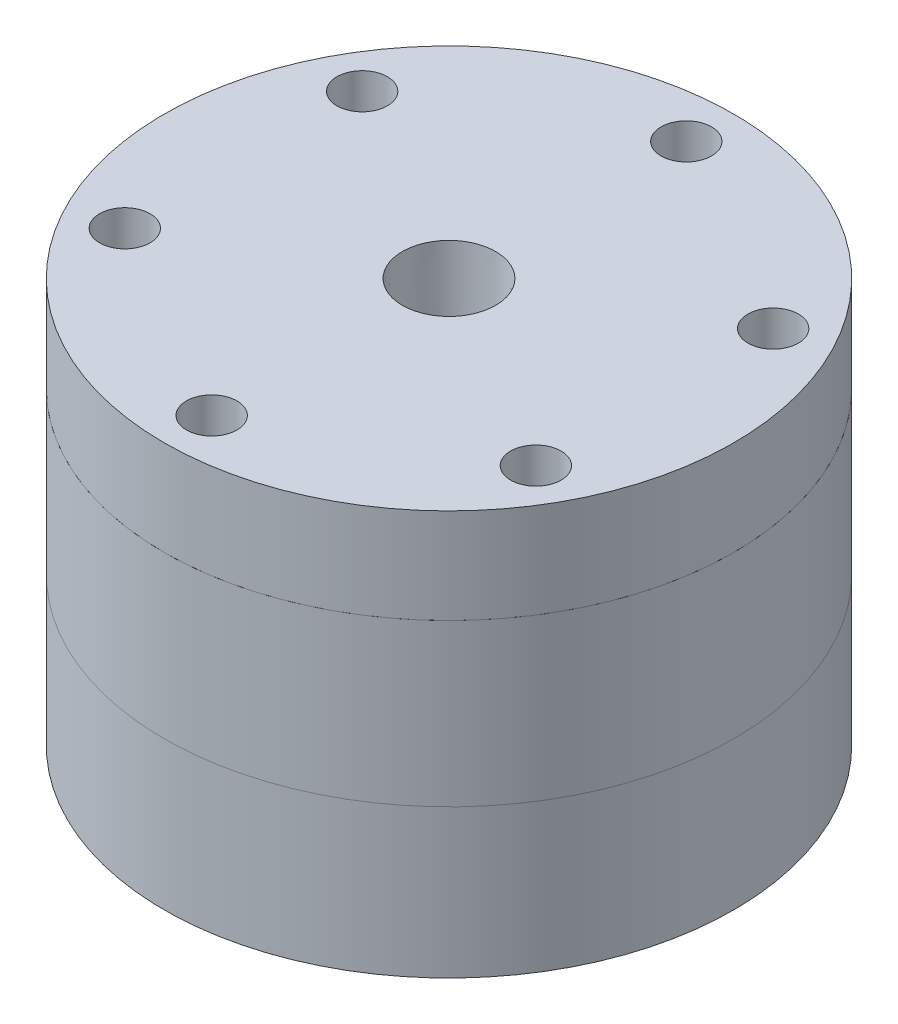
from build123d import *

# Parameters (mm, degrees)
SKETCH21_W          = 19.05
SKETCH21_H          = 13.4874
SKETCH13_R          = 38.1
BOSS_EXTRUDE1_DEPTH = 12.7
SKETCH15_W          = 3.3782
SKETCH15_H          = 54.1274
CIRPATTERN1_COUNT   = 6


with BuildPart() as part:
    # Sketch1 → Revolve1 (revolve)
    with BuildSketch(Plane.XY):
        Polygon((-25.5524, 0), (-38.1, 0), (-38.1, -21.59), (-25.5524, -21.59), (-25.5524, -18.8976), (-21.4884, -18.8976), (-21.4884, -21.59), (-11.9761, -21.59), (-11.9761, -19.6088), (-8.9027, -19.6088), (-8.9027, -21.59), (-7.62, -21.59), (-7.62, -18.415), (-10.795, -15.24), (-15.875, -15.24), (-15.875, 0), (-21.4884, 0), (-21.4884, -2.6924), (-25.5524, -2.6924), align=None)
    revolve(axis=Axis((0, -86.75, 0), (0, 1, 0)))


with BuildPart() as body_2:
    # Sketch21 → Revolve7 (revolve)
    with BuildSketch(Plane.XY):
        with Locations((-28.575, -28.3337)):
            Rectangle(SKETCH21_W, SKETCH21_H)
    revolve(axis=Axis((0, -86.75, 0), (0, 1, 0)))

    # Sketch4 → Revolve5 (revolve)
    with BuildSketch(Plane.XY):
        Polygon((-6.35, -35.0774), (-38.1, -35.0774), (-38.1, -41.4274), (-11.1125, -41.4274), (-6.35, -36.6649), align=None)
    revolve(axis=Axis((0, -86.75, 0), (0, 1, 0)))

    # Sketch10 → 1/4 NPT Tapped Hole3 (revolve, cut)
    with BuildSketch(Plane(origin=(-38.1, -30.6324, 0), x_dir=(0, 0, 1), z_dir=(0, 1, 0))):
        Polygon((0, 0), (0, 25.694347279), (5.5626, 22.352), (5.5626, 9.906), (5.943685794, 9.906), (6.2402847, 0), align=None)
    revolve(axis=Axis((-44.45, -30.6324, 0), (1, 0, 0)), mode=Mode.SUBTRACT)


with BuildPart() as body_3:
    # Sketch13 → Boss-Extrude1 (new body)
    with BuildSketch(Plane(origin=(0, 0, 0), x_dir=(1, 0, 0), z_dir=(0, 1, 0))):
        Circle(SKETCH13_R)
    extrude(amount=BOSS_EXTRUDE1_DEPTH)

    # Sketch17 → 1/4 NPT Tapped Hole4 (revolve, cut)
    with BuildSketch(Plane(origin=(0, 12.7, 0), x_dir=(0, 0, 1), z_dir=(1, 0, 0))):
        Polygon((0, 0), (0, 54.1274), (5.5626, 54.1274), (5.5626, 9.906), (5.943685794, 9.906), (6.2402847, 0), align=None)
    revolve(axis=Axis((0, 19.05, 0), (0, -1, 0)), mode=Mode.SUBTRACT)


with BuildPart() as f_1_4_clearance_hole1_tool:
    # Sketch15 → 1/4 Clearance Hole1 (revolve)
    with BuildSketch(Plane(origin=(-27.49630657, 12.7, -15.875), x_dir=(0, 0, 1), z_dir=(1, 0, 0))):
        with Locations((1.6891, 27.0637)):
            Rectangle(SKETCH15_W, SKETCH15_H)
    f_1_4_clearance_hole1 = revolve(axis=Axis((-27.49630657, 19.05, -15.875), (0, -1, 0)))


with BuildPart() as body_2_1:
    add(body_2.part)

    # 1/4 Clearance Hole1: cut by f_1_4_clearance_hole1_tool
    add(f_1_4_clearance_hole1_tool.part, mode=Mode.SUBTRACT)


with BuildPart() as body_3_1:
    add(body_3.part)

    # 1/4 Clearance Hole1: cut by f_1_4_clearance_hole1_tool
    add(f_1_4_clearance_hole1_tool.part, mode=Mode.SUBTRACT)


with BuildPart() as cirpattern1_tool:
    # CirPattern1: 1/4 Clearance Hole1 ×6 about axis
    cirpattern1_axis = Axis((0, 0, 0), (0, 1, 0))
    for i in range(1, CIRPATTERN1_COUNT):
        add(f_1_4_clearance_hole1.rotate(cirpattern1_axis, i * 360 / CIRPATTERN1_COUNT))


with BuildPart() as body_2_2:
    add(body_2_1.part)

    # CirPattern1: cut by cirpattern1_tool
    add(cirpattern1_tool.part, mode=Mode.SUBTRACT)


with BuildPart() as body_3_2:
    add(body_3_1.part)

    # CirPattern1: cut by cirpattern1_tool
    add(cirpattern1_tool.part, mode=Mode.SUBTRACT)


solid = Compound([part.part, body_2_2.part, body_3_2.part])
